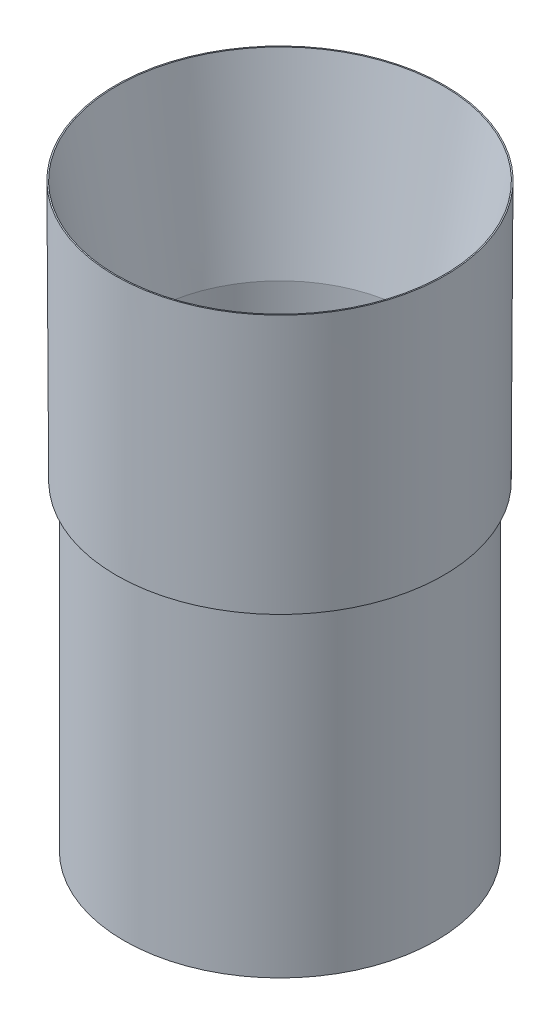
from build123d import *


with BuildPart() as part:
    # Sketch1 → Revolve1 (revolve)
    with BuildSketch(Plane.XY):
        Polygon((-49.53, 0), (-51.9176, 0), (-52.324, 82.548999625), (-51.943, 82.548999625), (-41.866089446, 25.4), (-41.866089446, 0), (-47.244, 0), (-47.244, -101.6), (-49.53, -101.6), align=None)
    revolve(axis=Axis((0, 0, 0), (0, 1, 0)))


solid = part.part
